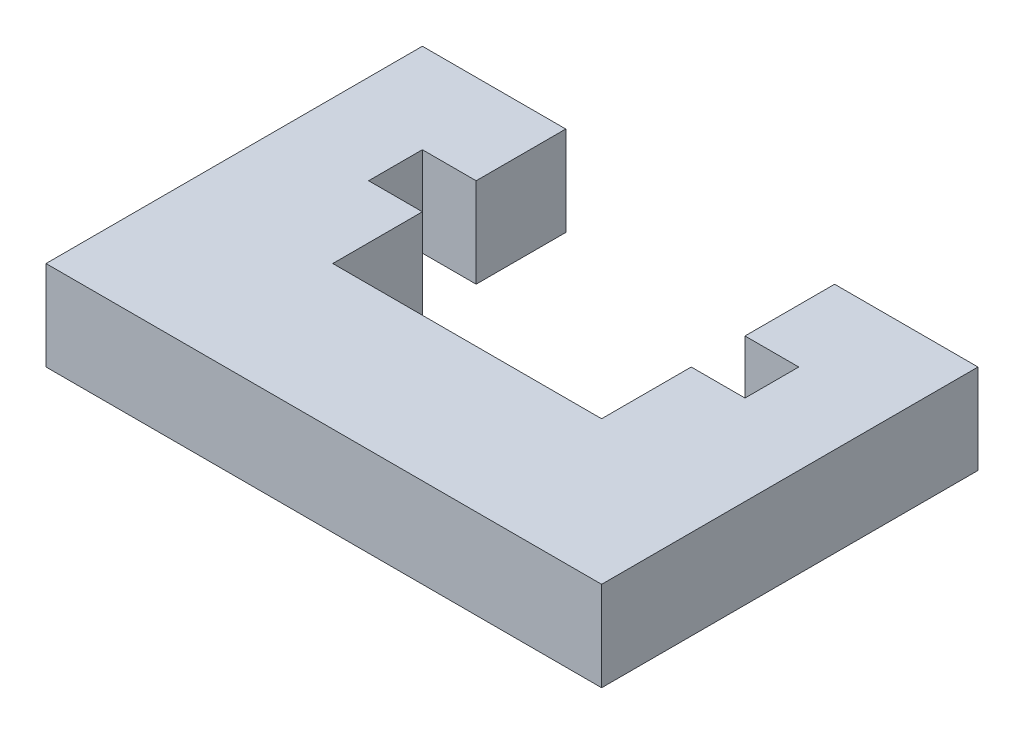
from build123d import *

# Parameters (mm, degrees)
EXTRUDE_1_DEPTH     = 5
CUT_EXTRUDE_START   = -5
SKETCH_2_W          = 21
SKETCH_2_H          = 3
CUT_EXTRUDE_1_DEPTH = 5


with BuildPart() as part:
    # 草图1 → 凸台-拉伸1 (new body)
    with BuildSketch(Plane(origin=(0, 0, 0), x_dir=(1, 0, 0), z_dir=(0, 1, 0))):
        Polygon((0, 21), (0, 0), (31, 0), (31, 21), (23, 21), (23, 8), (8, 8), (8, 21), align=None)
    extrude(amount=EXTRUDE_1_DEPTH)

    # 草图2 → 切除-拉伸1 (cut)
    with BuildSketch(Plane(origin=(0, 5, 0), x_dir=(1, 0, 0), z_dir=(0, 1, 0)).offset(CUT_EXTRUDE_START)):
        with Locations((15.5, 14.5)):
            Rectangle(SKETCH_2_W, SKETCH_2_H)
    extrude(amount=CUT_EXTRUDE_1_DEPTH, mode=Mode.SUBTRACT)


solid = part.part
